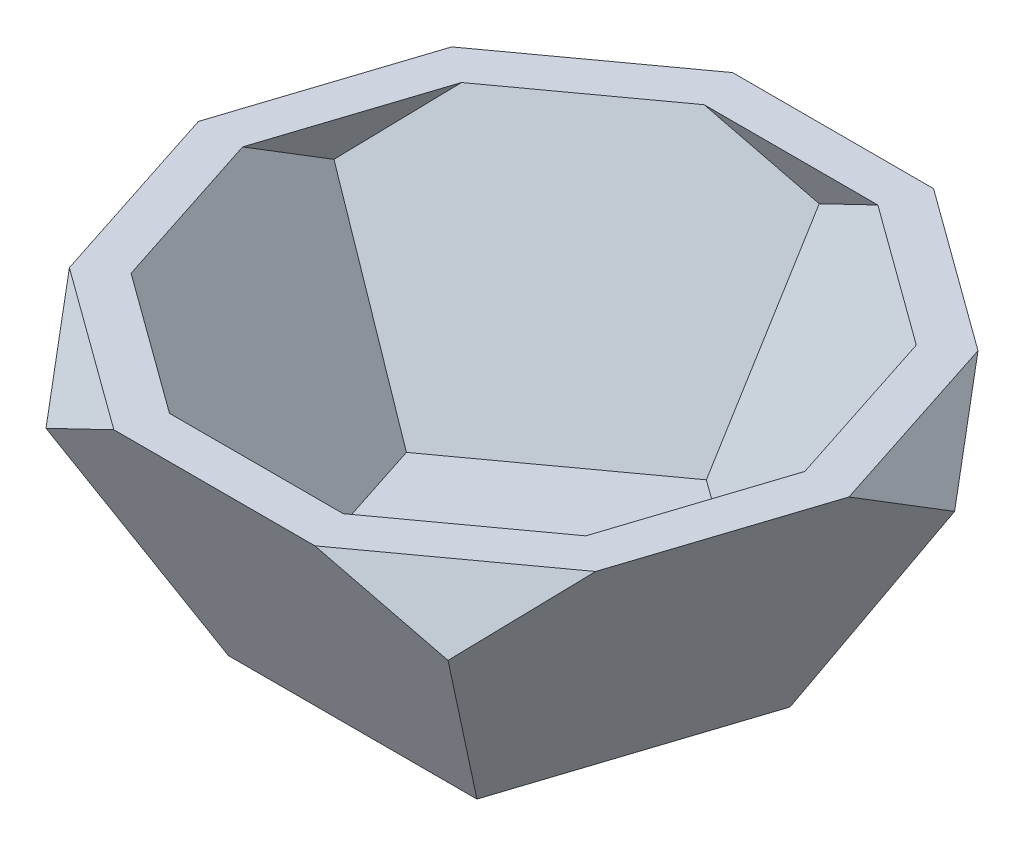
from build123d import *

# Parameters (mm, degrees)
BOSS_EXTRUDE1_DEPTH = 33.2486
BOSS_EXTRUDE1_TAPER = -26.56505118
SKETCH2_OUTSIDE_W   = 117.17
SKETCH2_OUTSIDE_H   = 114.076
CUT_EXTRUDE1_DEPTH  = 33.2486
CUT_EXTRUDE1_TAPER  = 26.56505118
SCALE1_SCALE        = 1.125
SKETCH3_W           = 93.211542344
SKETCH3_H           = 68.986167311
CUT_EXTRUDE2_DEPTH  = 37.980872387
SHELL1_T            = -2.54


with BuildPart() as part:
    # Sketch1 → Boss-Extrude1 (new body)
    with BuildSketch(Plane(origin=(0, 0, 0), x_dir=(1, 0, 0), z_dir=(0, 1, 0))):
        Polygon((12.078417757, 3.924515829), (0, 12.7), (-12.078417757, 3.924515829), (-7.464872704, -10.274515829), (7.464872704, -10.274515829), align=None)
    extrude(amount=BOSS_EXTRUDE1_DEPTH, taper=BOSS_EXTRUDE1_TAPER)

    # Sketch2 outside → Cut-Extrude1 (cut)
    with BuildSketch(Plane(origin=(0, 33.2486, 0), x_dir=(1, 0, 0), z_dir=(0, 1, 0))):
        with Locations((0, 3.175)):
            Rectangle(SKETCH2_OUTSIDE_W, SKETCH2_OUTSIDE_H)
        Polygon((7.464872704, 10.274515829), (-7.464872704, 10.274515829), (-12.078417757, -3.924515829), (0, -12.7), (12.078417757, -3.924515829), align=None, mode=Mode.SUBTRACT)
    extrude(amount=-CUT_EXTRUDE1_DEPTH, taper=CUT_EXTRUDE1_TAPER, mode=Mode.SUBTRACT)


with BuildPart() as part_1:
    # Scale1: scaled about (0, 0, 0)
    add(part.part.scale(SCALE1_SCALE))

    # Sketch3 → Cut-Extrude2 (cut, through all)
    with BuildSketch(Plane(origin=(0, 18.7023375, 0), x_dir=(1, 0, 0), z_dir=(0, 1, 0))):
        with Locations((6.510218593, 0.168740009)):
            Rectangle(SKETCH3_W, SKETCH3_H)
    extrude(amount=CUT_EXTRUDE2_DEPTH, mode=Mode.SUBTRACT)

    # Shell1
    shell1_openings = [part_1.faces().sort_by_distance(p)[0] for p in [
        (0, 18.7023375, 0),
    ]]
    offset(amount=SHELL1_T, openings=shell1_openings, kind=Kind.INTERSECTION)


solid = part_1.part
